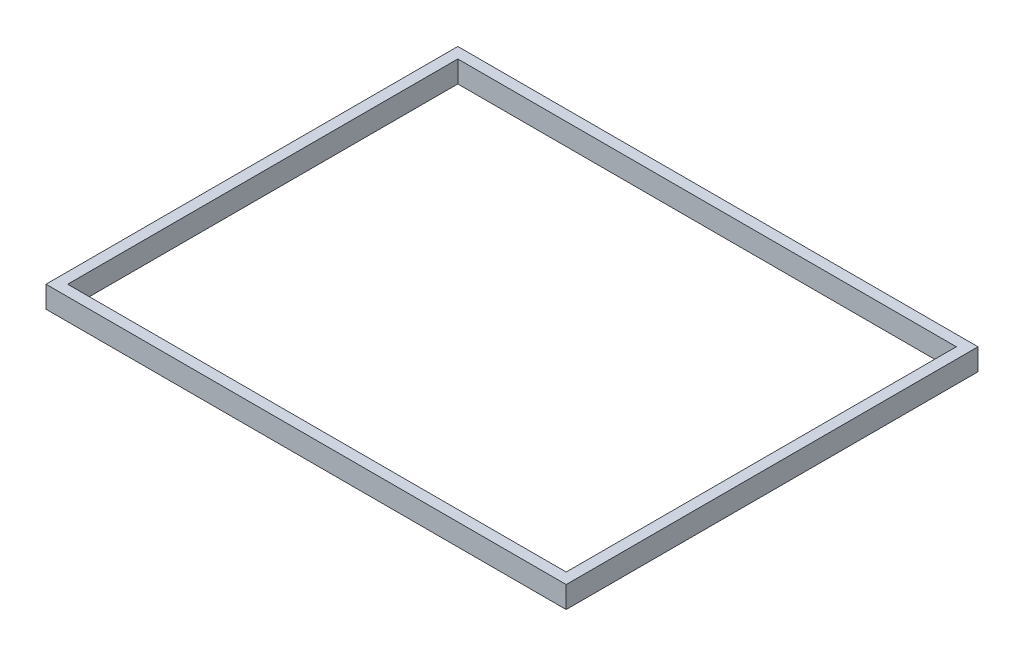
from build123d import *

# Parameters (mm, degrees)
SKETCH1_W           = 480
SKETCH1_H           = 380
SKETCH1_W_2         = 460
SKETCH1_H_2         = 360
BOSS_EXTRUDE1_DEPTH = 20


with BuildPart() as part:
    # Sketch1 → Boss-Extrude1 (new body)
    with BuildSketch(Plane(origin=(0, 0, 0), x_dir=(1, 0, 0), z_dir=(0, 1, 0))):
        Rectangle(SKETCH1_W, SKETCH1_H)
        Rectangle(SKETCH1_W_2, SKETCH1_H_2, mode=Mode.SUBTRACT)
    extrude(amount=BOSS_EXTRUDE1_DEPTH)


solid = part.part
